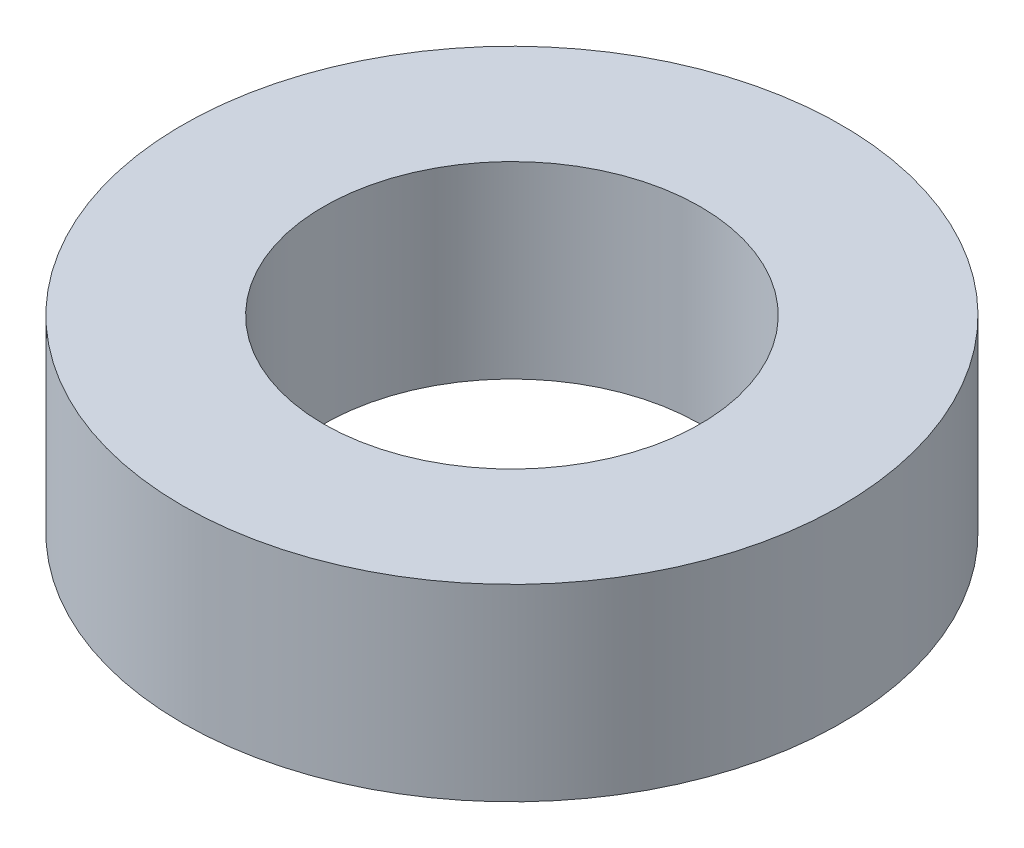
from build123d import *

# Parameters (mm, degrees)
SKETCH1_R           = 11.1125
SKETCH1_R_2         = 6.35
BOSS_EXTRUDE1_DEPTH = 6.35


with BuildPart() as part:
    # Sketch1 → Boss-Extrude1 (new body)
    with BuildSketch(Plane(origin=(0, 0, 0), x_dir=(1, 0, 0), z_dir=(0, 1, 0))):
        Circle(SKETCH1_R)
        Circle(SKETCH1_R_2, mode=Mode.SUBTRACT)
    extrude(amount=BOSS_EXTRUDE1_DEPTH)


solid = part.part
